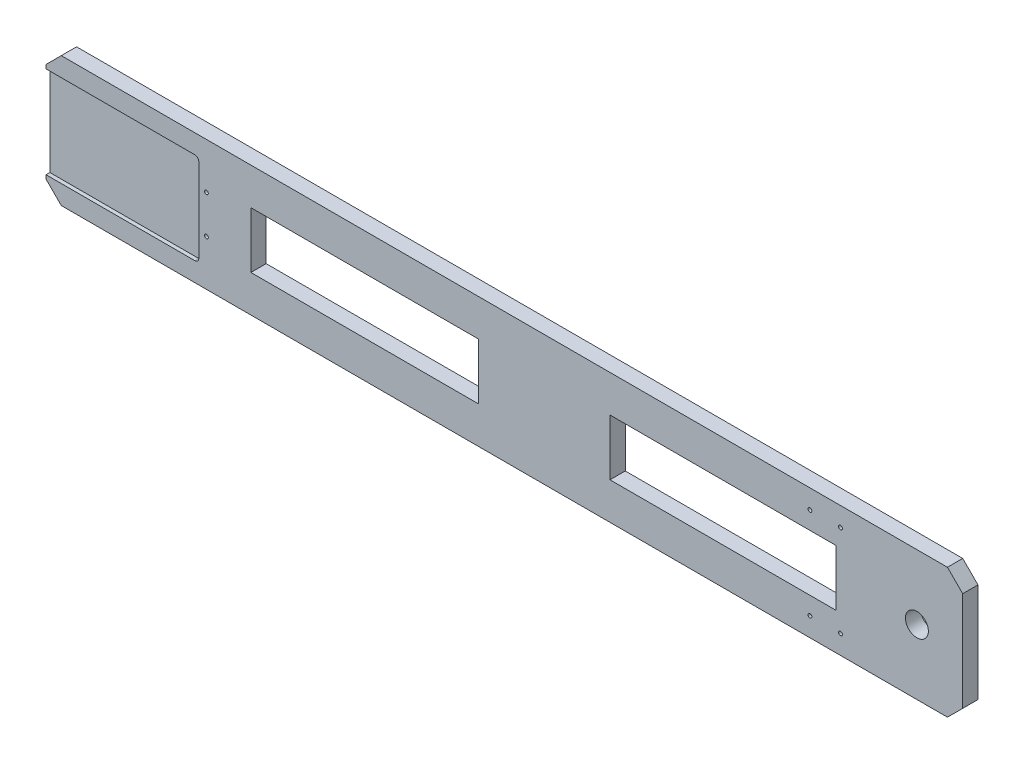
from build123d import *

# Parameters (mm, degrees)
EXTRUDE_1_DEPTH             = 20
SKETCH_2_R                  = 15
CUT_EXTRUDE_1_DEPTH         = 21
CUT_EXTRUDE_2_DEPTH         = 5
HOLE_WIZARD_M6_1_D          = 5
HOLE_WIZARD_M6_1_DEPTH      = 15
HOLE_WIZARD_M6_1_TIP        = 1.502151548
HOLE_WIZARD_M6_2_AT_2_COUNT = 2
HOLE_WIZARD_M6_2_AT_2_PITCH = 40
MM_1_D                      = 12
MM_1_DEPTH                  = 2
MM_1_TIP                    = 3.605163714
SKETCH_19_W                 = 298.256507651
SKETCH_19_H                 = 73.483487392
SKETCH_19_W_2               = 296.09522861
CUT_EXTRUDE_3_DEPTH         = 21


with BuildPart() as part:
    # 草图1 → 凸台-拉伸1 (new body)
    with BuildSketch(Plane.XY):
        Polygon((-580, 85), (-600, 65), (-600, -65), (-580, -85), (580, -85), (600, -65), (600, 65), (580, 85), align=None)
    extrude(amount=EXTRUDE_1_DEPTH)

    # 草图2 → 切除-拉伸1 (cut, through all)
    with BuildSketch(Plane.XY.offset(20)):
        with Locations((540, 0)):
            Circle(SKETCH_2_R)
    extrude(amount=-CUT_EXTRUDE_1_DEPTH, mode=Mode.SUBTRACT)

    # 草图3 → 切除-拉伸2 (cut)
    with BuildSketch(Plane.XY.offset(20)):
        with BuildLine():
            Line((-800, -60), (-405, -60))
            ThreePointArc((-405, -60), (-401.464466094, -58.535533906), (-400, -55))
            Line((-400, -55), (-400, 55))
            ThreePointArc((-400, 55), (-401.464466094, 58.535533906), (-405, 60))
            Line((-405, 60), (-800, 60))
            Line((-800, 60), (-800, -60))
        make_face()
    extrude(amount=-CUT_EXTRUDE_2_DEPTH, mode=Mode.SUBTRACT)

    # M6 螺纹孔1
    with Locations(Plane(origin=(-390, 25, 20), x_dir=(1, 0, 0), z_dir=(0, 0, 1))):
        with Locations((0, 0), (0, -50)):
            Hole(HOLE_WIZARD_M6_1_D / 2, depth=HOLE_WIZARD_M6_1_DEPTH)
            with Locations((0, 0, -(HOLE_WIZARD_M6_1_DEPTH + HOLE_WIZARD_M6_1_TIP / 2))):  # 118° drill point
                Cone(0, HOLE_WIZARD_M6_1_D / 2, HOLE_WIZARD_M6_1_TIP, mode=Mode.SUBTRACT)

    # 草图16 → M6 螺纹孔2 (revolve, cut)
    with BuildSketch(Plane(origin=(400, 60, 20), x_dir=(0, -1, 0), z_dir=(1, 0, 0))):
        Polygon((0, 0), (0, 16.502151548), (2.5, 15), (2.5, 0), align=None)
    hole_wizard_m6_2 = revolve(axis=Axis((400, 60, 26.35), (0, 0, -1)), mode=Mode.SUBTRACT)

    # M6 螺纹孔2 at 2: M6 螺纹孔2 ×2
    with Locations(*[(i * HOLE_WIZARD_M6_2_AT_2_PITCH, 0, 0) for i in range(1, HOLE_WIZARD_M6_2_AT_2_COUNT)]):
        add(hole_wizard_m6_2, mode=Mode.SUBTRACT)

    # 镜向2: M6 螺纹孔2 across plane
    add(hole_wizard_m6_2.mirror(Plane.ZX), mode=Mode.SUBTRACT)

    # 镜向2 copy 1 sketch → 镜向2 copy 1 (revolve, cut)
    with BuildSketch(Plane(origin=(440, -60, 20), x_dir=(0, 1, 0), z_dir=(1, 0, 0))):
        Polygon((0, 0), (0, -16.502151548), (2.5, -15), (2.5, 0), align=None)
    revolve(axis=Axis((440, -60, 26.35), (0, 0, 1)), mode=Mode.SUBTRACT)

    # 大小mm 暗销孔1
    with Locations(Plane(origin=(0, 0, 0), x_dir=(-1, 0, 0), z_dir=(0, 0, -1))):
        with Locations((-250, 65), (250, 65), (250, -65), (-250, -65)):
            Hole(MM_1_D / 2, depth=MM_1_DEPTH)
            with Locations((0, 0, -(MM_1_DEPTH + MM_1_TIP / 2))):  # 118° drill point
                Cone(0, MM_1_D / 2, MM_1_TIP, mode=Mode.SUBTRACT)

    # 草图19 → 切除-拉伸3 (cut, through all)
    with BuildSketch(Plane.XY.offset(20)):
        with Locations((-182.687664533, 0)):
            Rectangle(SKETCH_19_W, SKETCH_19_H)
        with Locations((286.309887354, 0)):
            Rectangle(SKETCH_19_W_2, SKETCH_19_H)
    extrude(amount=-CUT_EXTRUDE_3_DEPTH, mode=Mode.SUBTRACT)


solid = part.part
